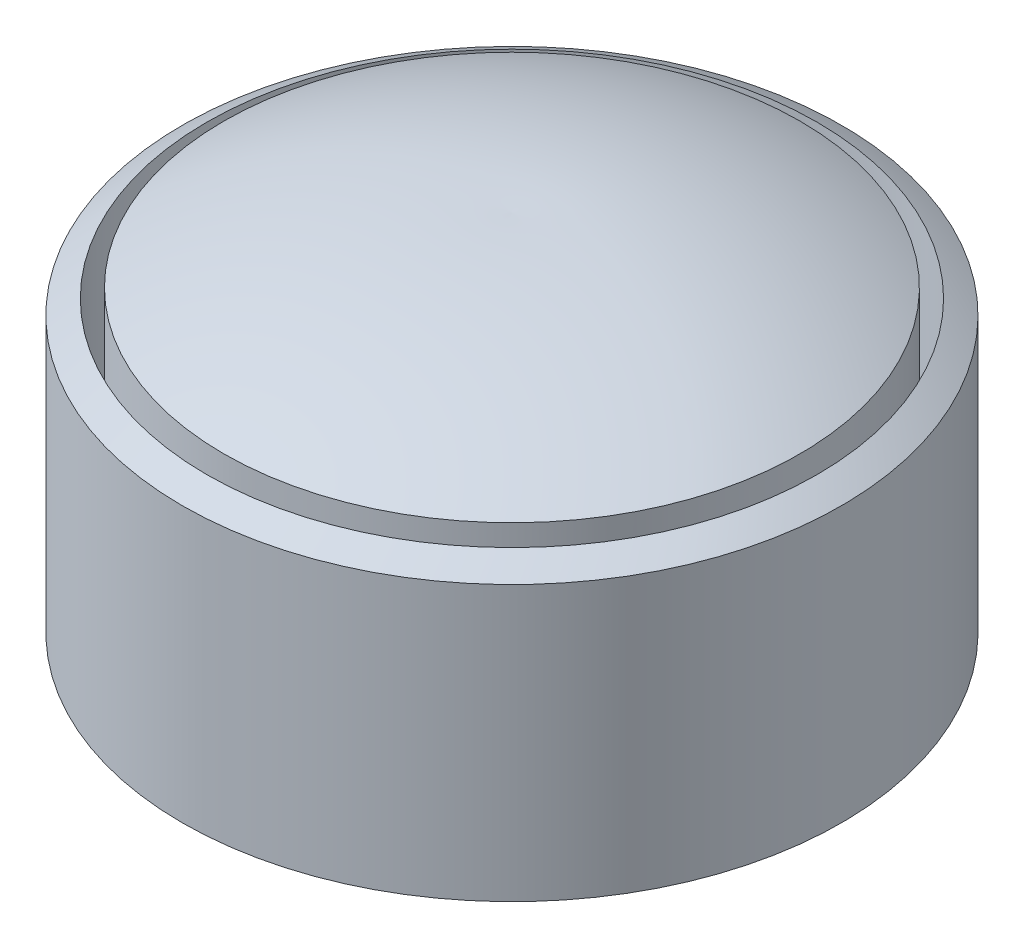
from build123d import *

# Parameters (mm, degrees)
SKETCH2_R          = 4.44536043
SKETCH2_R_2        = 4.196679611
CUT_EXTRUDE1_DEPTH = 4.5


with BuildPart() as part:
    # Sketch1 → Revolve1 (revolve)
    with BuildSketch(Plane.XY):
        with BuildLine():
            Line((0, 0), (0, 4))
            add(Edge.make_bspline(
                [(0, 4), (2.184134462, 5.397553825), (4.8, 5.3)],
                knots=[0, 0, 0, 1, 1, 1], degree=2))
            Line((4.8, 5.3), (4.8, 0))
            Line((4.8, 0), (0, 0))
        make_face()
    revolve(axis=Axis((4.8, 5.3, 0), (0, -1, 0)))

    # Sketch2 → Cut-Extrude1 (cut)
    with BuildSketch(Plane.XZ):
        with Locations((4.8, 0)):
            Circle(SKETCH2_R)
        with Locations((4.8, 0)):
            Circle(SKETCH2_R_2, mode=Mode.SUBTRACT)
    extrude(amount=-CUT_EXTRUDE1_DEPTH, mode=Mode.SUBTRACT)


solid = part.part
